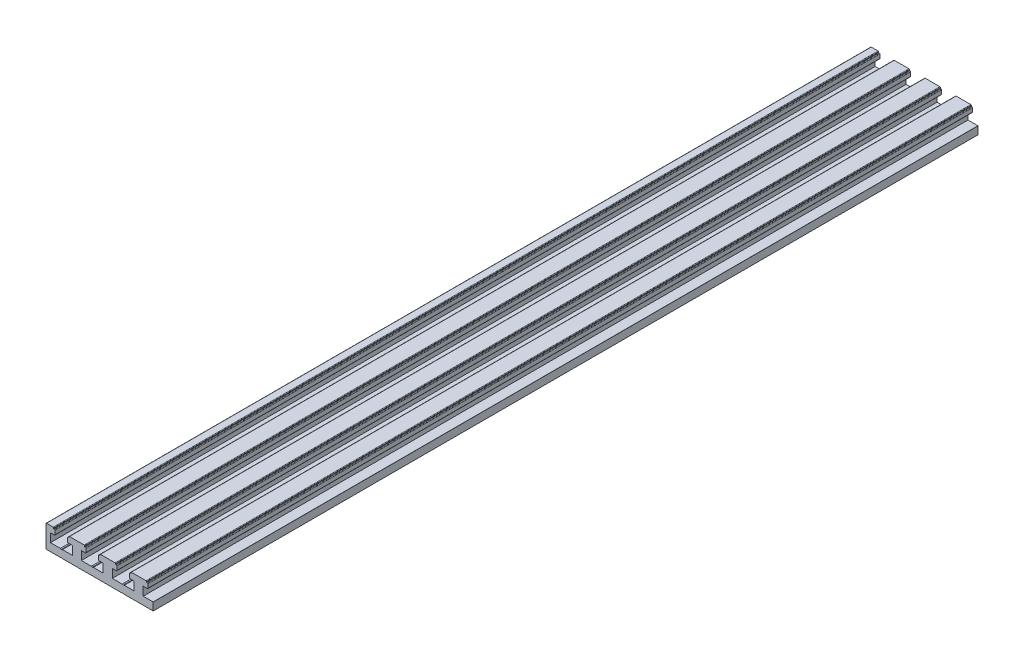
from build123d import *

# Parameters (mm, degrees)
RAWPART_DEPTH                                  = 400
CSK_FOR_M3_FLAT_HEAD_MACHINE_SCREW1_AT_2_COUNT = 2
CSK_FOR_M3_FLAT_HEAD_MACHINE_SCREW1_AT_2_PITCH = 30
CSK_FOR_M3_FLAT_HEAD_MACHINE_SCREW1_AT_3_COUNT = 2
CSK_FOR_M3_FLAT_HEAD_MACHINE_SCREW1_AT_3_PITCH = 266.692658283
CSK_FOR_M3_FLAT_HEAD_MACHINE_SCREW1_AT_4_COUNT = 2
CSK_FOR_M3_FLAT_HEAD_MACHINE_SCREW1_AT_4_PITCH = 264.999950909
SKETCH6_W                                      = 26.849295337
SKETCH6_H                                      = 24.501338483
CUTUNNECESSARYHALF_DEPTH                       = 401.0000001


with BuildPart() as part:
    # Sketch1 → RawPart (new body)
    with BuildSketch(Plane(origin=(0, 0, 0), x_dir=(-1, 0, 0), z_dir=(0, 0, -1))):
        with BuildLine():
            Line((-37.45, 8.85), (-37.45, -1.65))
            ThreePointArc((-37.45, -1.65), (-37.376776695, -1.826776695), (-37.2, -1.9))
            Line((-37.2, -1.9), (-30.543629459, -1.9))
            ThreePointArc((-30.543629459, -1.9), (-30.500649598, -1.896277753), (-30.458949592, -1.885221853))
            Line((-30.458949592, -1.885221853), (-30, -1.72))
            Line((-30, -1.72), (-29.541050408, -1.885221853))
            ThreePointArc((-29.541050408, -1.885221853), (-29.499350402, -1.896277753), (-29.456370541, -1.9))
            Line((-29.456370541, -1.9), (-15.543629459, -1.9))
            ThreePointArc((-15.543629459, -1.9), (-15.500649598, -1.896277753), (-15.458949592, -1.885221853))
            Line((-15.458949592, -1.885221853), (-15, -1.72))
            Line((-15, -1.72), (-14.541050408, -1.885221853))
            ThreePointArc((-14.541050408, -1.885221853), (-14.499350402, -1.896277753), (-14.456370541, -1.9))
            Line((-14.456370541, -1.9), (-0.543629459, -1.9))
            ThreePointArc((-0.543629459, -1.9), (-0.500649598, -1.896277753), (-0.458949592, -1.885221853))
            Line((-0.458949592, -1.885221853), (0, -1.72))
            Line((0, -1.72), (0.458949592, -1.885221853))
            ThreePointArc((0.458949592, -1.885221853), (0.500649598, -1.896277753), (0.543629459, -1.9))
            Line((0.543629459, -1.9), (14.456370541, -1.9))
            ThreePointArc((14.456370541, -1.9), (14.499350402, -1.896277753), (14.541050408, -1.885221853))
            Line((14.541050408, -1.885221853), (15, -1.72))
            Line((15, -1.72), (15.458949592, -1.885221853))
            ThreePointArc((15.458949592, -1.885221853), (15.500649598, -1.896277753), (15.543629459, -1.9))
            Line((15.543629459, -1.9), (29.456370541, -1.9))
            ThreePointArc((29.456370541, -1.9), (29.499350402, -1.896277753), (29.541050408, -1.885221853))
            Line((29.541050408, -1.885221853), (30, -1.72))
            Line((30, -1.72), (30.458949592, -1.885221853))
            ThreePointArc((30.458949592, -1.885221853), (30.500649598, -1.896277753), (30.543629459, -1.9))
            Line((30.543629459, -1.9), (37.2, -1.9))
            ThreePointArc((37.2, -1.9), (37.376776695, -1.826776695), (37.45, -1.65))
            Line((37.45, -1.65), (37.45, 8.85))
            ThreePointArc((37.45, 8.85), (37.376776695, 9.026776695), (37.2, 9.1))
            Line((37.2, 9.1), (33.95, 9.1))
            ThreePointArc((33.95, 9.1), (33.773223305, 9.026776695), (33.7, 8.85))
            Line((33.7, 8.85), (33.7, 8.5))
            Line((33.7, 8.5), (33.32, 8.5))
            ThreePointArc((33.32, 8.5), (33.143223305, 8.426776695), (33.07, 8.25))
            Line((33.07, 8.25), (33.07, 6.35))
            ThreePointArc((33.07, 6.35), (33.143223305, 6.173223305), (33.32, 6.1))
            Line((33.32, 6.1), (35.3, 6.1))
            Line((35.3, 6.1), (35.3, 1.9))
            Line((35.3, 1.9), (30.543629459, 1.9))
            ThreePointArc((30.543629459, 1.9), (30.500649598, 1.896277753), (30.458949592, 1.885221853))
            Line((30.458949592, 1.885221853), (30, 1.72))
            Line((30, 1.72), (29.541050408, 1.885221853))
            ThreePointArc((29.541050408, 1.885221853), (29.499350402, 1.896277753), (29.456370541, 1.9))
            Line((29.456370541, 1.9), (24.7, 1.9))
            Line((24.7, 1.9), (24.7, 6.1))
            Line((24.7, 6.1), (26.68, 6.1))
            ThreePointArc((26.68, 6.1), (26.856776695, 6.173223305), (26.93, 6.35))
            Line((26.93, 6.35), (26.93, 8.25))
            ThreePointArc((26.93, 8.25), (26.856776695, 8.426776695), (26.68, 8.5))
            Line((26.68, 8.5), (26.3, 8.5))
            Line((26.3, 8.5), (26.3, 8.85))
            ThreePointArc((26.3, 8.85), (26.226776695, 9.026776695), (26.05, 9.1))
            Line((26.05, 9.1), (18.95, 9.1))
            ThreePointArc((18.95, 9.1), (18.773223305, 9.026776695), (18.7, 8.85))
            Line((18.7, 8.85), (18.7, 8.5))
            Line((18.7, 8.5), (18.32, 8.5))
            ThreePointArc((18.32, 8.5), (18.143223305, 8.426776695), (18.07, 8.25))
            Line((18.07, 8.25), (18.07, 6.35))
            ThreePointArc((18.07, 6.35), (18.143223305, 6.173223305), (18.32, 6.1))
            Line((18.32, 6.1), (20.3, 6.1))
            Line((20.3, 6.1), (20.3, 1.9))
            Line((20.3, 1.9), (15.543629459, 1.9))
            ThreePointArc((15.543629459, 1.9), (15.500649598, 1.896277753), (15.458949592, 1.885221853))
            Line((15.458949592, 1.885221853), (15, 1.72))
            Line((15, 1.72), (14.541050408, 1.885221853))
            ThreePointArc((14.541050408, 1.885221853), (14.499350402, 1.896277753), (14.456370541, 1.9))
            Line((14.456370541, 1.9), (9.7, 1.9))
            Line((9.7, 1.9), (9.7, 6.1))
            Line((9.7, 6.1), (11.68, 6.1))
            ThreePointArc((11.68, 6.1), (11.856776695, 6.173223305), (11.93, 6.35))
            Line((11.93, 6.35), (11.93, 8.25))
            ThreePointArc((11.93, 8.25), (11.856776695, 8.426776695), (11.68, 8.5))
            Line((11.68, 8.5), (11.3, 8.5))
            Line((11.3, 8.5), (11.3, 8.85))
            ThreePointArc((11.3, 8.85), (11.226776695, 9.026776695), (11.05, 9.1))
            Line((11.05, 9.1), (3.95, 9.1))
            ThreePointArc((3.95, 9.1), (3.773223305, 9.026776695), (3.7, 8.85))
            Line((3.7, 8.85), (3.7, 8.5))
            Line((3.7, 8.5), (3.32, 8.5))
            ThreePointArc((3.32, 8.5), (3.143223305, 8.426776695), (3.07, 8.25))
            Line((3.07, 8.25), (3.07, 6.35))
            ThreePointArc((3.07, 6.35), (3.143223305, 6.173223305), (3.32, 6.1))
            Line((3.32, 6.1), (5.3, 6.1))
            Line((5.3, 6.1), (5.3, 1.9))
            Line((5.3, 1.9), (0.543629459, 1.9))
            ThreePointArc((0.543629459, 1.9), (0.500649598, 1.896277753), (0.458949592, 1.885221853))
            Line((0.458949592, 1.885221853), (0, 1.72))
            Line((0, 1.72), (-0.458949592, 1.885221853))
            ThreePointArc((-0.458949592, 1.885221853), (-0.500649598, 1.896277753), (-0.543629459, 1.9))
            Line((-0.543629459, 1.9), (-5.3, 1.9))
            Line((-5.3, 1.9), (-5.3, 6.1))
            Line((-5.3, 6.1), (-3.32, 6.1))
            ThreePointArc((-3.32, 6.1), (-3.143223305, 6.173223305), (-3.07, 6.35))
            Line((-3.07, 6.35), (-3.07, 8.25))
            ThreePointArc((-3.07, 8.25), (-3.143223305, 8.426776695), (-3.32, 8.5))
            Line((-3.32, 8.5), (-3.7, 8.5))
            Line((-3.7, 8.5), (-3.7, 8.85))
            ThreePointArc((-3.7, 8.85), (-3.773223305, 9.026776695), (-3.95, 9.1))
            Line((-3.95, 9.1), (-11.05, 9.1))
            ThreePointArc((-11.05, 9.1), (-11.226776695, 9.026776695), (-11.3, 8.85))
            Line((-11.3, 8.85), (-11.3, 8.5))
            Line((-11.3, 8.5), (-11.68, 8.5))
            ThreePointArc((-11.68, 8.5), (-11.856776695, 8.426776695), (-11.93, 8.25))
            Line((-11.93, 8.25), (-11.93, 6.35))
            ThreePointArc((-11.93, 6.35), (-11.856776695, 6.173223305), (-11.68, 6.1))
            Line((-11.68, 6.1), (-9.7, 6.1))
            Line((-9.7, 6.1), (-9.7, 1.9))
            Line((-9.7, 1.9), (-14.456370541, 1.9))
            ThreePointArc((-14.456370541, 1.9), (-14.499350402, 1.896277753), (-14.541050408, 1.885221853))
            Line((-14.541050408, 1.885221853), (-15, 1.72))
            Line((-15, 1.72), (-15.458949592, 1.885221853))
            ThreePointArc((-15.458949592, 1.885221853), (-15.500649598, 1.896277753), (-15.543629459, 1.9))
            Line((-15.543629459, 1.9), (-20.3, 1.9))
            Line((-20.3, 1.9), (-20.3, 6.1))
            Line((-20.3, 6.1), (-18.32, 6.1))
            ThreePointArc((-18.32, 6.1), (-18.143223305, 6.173223305), (-18.07, 6.35))
            Line((-18.07, 6.35), (-18.07, 8.25))
            ThreePointArc((-18.07, 8.25), (-18.143223305, 8.426776695), (-18.32, 8.5))
            Line((-18.32, 8.5), (-18.7, 8.5))
            Line((-18.7, 8.5), (-18.7, 8.85))
            ThreePointArc((-18.7, 8.85), (-18.773223305, 9.026776695), (-18.95, 9.1))
            Line((-18.95, 9.1), (-26.05, 9.1))
            ThreePointArc((-26.05, 9.1), (-26.226776695, 9.026776695), (-26.3, 8.85))
            Line((-26.3, 8.85), (-26.3, 8.5))
            Line((-26.3, 8.5), (-26.68, 8.5))
            ThreePointArc((-26.68, 8.5), (-26.856776695, 8.426776695), (-26.93, 8.25))
            Line((-26.93, 8.25), (-26.93, 6.35))
            ThreePointArc((-26.93, 6.35), (-26.856776695, 6.173223305), (-26.68, 6.1))
            Line((-26.68, 6.1), (-24.7, 6.1))
            Line((-24.7, 6.1), (-24.7, 1.9))
            Line((-24.7, 1.9), (-29.456370541, 1.9))
            ThreePointArc((-29.456370541, 1.9), (-29.499350402, 1.896277753), (-29.541050408, 1.885221853))
            Line((-29.541050408, 1.885221853), (-30, 1.72))
            Line((-30, 1.72), (-30.458949592, 1.885221853))
            ThreePointArc((-30.458949592, 1.885221853), (-30.500649598, 1.896277753), (-30.543629459, 1.9))
            Line((-30.543629459, 1.9), (-35.3, 1.9))
            Line((-35.3, 1.9), (-35.3, 6.1))
            Line((-35.3, 6.1), (-33.32, 6.1))
            ThreePointArc((-33.32, 6.1), (-33.143223305, 6.173223305), (-33.07, 6.35))
            Line((-33.07, 6.35), (-33.07, 8.25))
            ThreePointArc((-33.07, 8.25), (-33.143223305, 8.426776695), (-33.32, 8.5))
            Line((-33.32, 8.5), (-33.7, 8.5))
            Line((-33.7, 8.5), (-33.7, 8.85))
            ThreePointArc((-33.7, 8.85), (-33.773223305, 9.026776695), (-33.95, 9.1))
            Line((-33.95, 9.1), (-37.2, 9.1))
            ThreePointArc((-37.2, 9.1), (-37.376776695, 9.026776695), (-37.45, 8.85))
        make_face()
    extrude(amount=-RAWPART_DEPTH)

    # Sketch2 → CSK for M3 Flat Head Machine Screw1 (revolve, cut)
    with BuildSketch(Plane(origin=(-30, 1.9, 65), x_dir=(0, 0, 1), z_dir=(1, 0, 0))):
        Polygon((0, 0), (0, 3.8), (1.6, 3.8), (1.6, 1.9), (3, 0.5), (3, 0), align=None)
    csk_for_m3_flat_head_machine_screw1 = revolve(axis=Axis((-30, 8.25, 65), (0, -1, 0)), mode=Mode.SUBTRACT)

    # CSK for M3 Flat Head Machine Screw1 at 2: CSK for M3 Flat Head Machine Screw1 ×2
    with Locations(*[(i * CSK_FOR_M3_FLAT_HEAD_MACHINE_SCREW1_AT_2_PITCH, 0, 0) for i in range(1, CSK_FOR_M3_FLAT_HEAD_MACHINE_SCREW1_AT_2_COUNT)]):
        add(csk_for_m3_flat_head_machine_screw1, mode=Mode.SUBTRACT)

    # CSK for M3 Flat Head Machine Screw1 at 3: CSK for M3 Flat Head Machine Screw1 ×2
    with Locations(*[Vector(0.112489036, 0, 0.993652966) * (i * CSK_FOR_M3_FLAT_HEAD_MACHINE_SCREW1_AT_3_PITCH) for i in range(1, CSK_FOR_M3_FLAT_HEAD_MACHINE_SCREW1_AT_3_COUNT)]):
        add(csk_for_m3_flat_head_machine_screw1, mode=Mode.SUBTRACT)

    # CSK for M3 Flat Head Machine Screw1 at 4: CSK for M3 Flat Head Machine Screw1 ×2
    with Locations(*[(0, 0, i * CSK_FOR_M3_FLAT_HEAD_MACHINE_SCREW1_AT_4_PITCH) for i in range(1, CSK_FOR_M3_FLAT_HEAD_MACHINE_SCREW1_AT_4_COUNT)]):
        add(csk_for_m3_flat_head_machine_screw1, mode=Mode.SUBTRACT)

    # Sketch6 → CutUnnecessaryHalf (cut, through all)
    with BuildSketch(Plane(origin=(0, 0, 0), x_dir=(-1, 0, 0), z_dir=(0, 0, -1))):
        with Locations((-27.974647669, 2.344920301)):
            Rectangle(SKETCH6_W, SKETCH6_H)
    extrude(amount=-CUTUNNECESSARYHALF_DEPTH, mode=Mode.SUBTRACT)


solid = part.part
